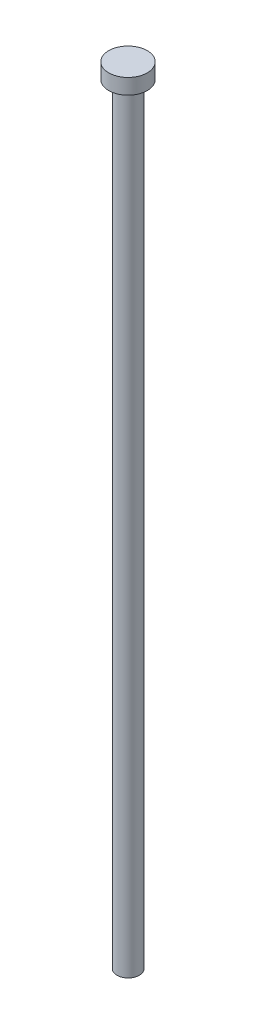
from build123d import *

# Parameters (mm, degrees)
SKETCH1_R           = 1.45
BOSS_EXTRUDE1_DEPTH = 100
SKETCH3_R           = 2.5
BOSS_EXTRUDE3_DEPTH = 2


with BuildPart() as part:
    # Sketch1 → Boss-Extrude1 (new body)
    with BuildSketch(Plane(origin=(0, 0, 0), x_dir=(1, 0, 0), z_dir=(0, 1, 0))):
        with Locations((-0.021698454, 0.046266125)):
            Circle(SKETCH1_R)
    extrude(amount=BOSS_EXTRUDE1_DEPTH)

    # Sketch3 → Boss-Extrude3 (add)
    with BuildSketch(Plane(origin=(0, 100, 0), x_dir=(1, 0, 0), z_dir=(0, 1, 0))):
        with Locations((0.010729748, -0.006302729)):
            Circle(SKETCH3_R)
    extrude(amount=BOSS_EXTRUDE3_DEPTH)


solid = part.part
